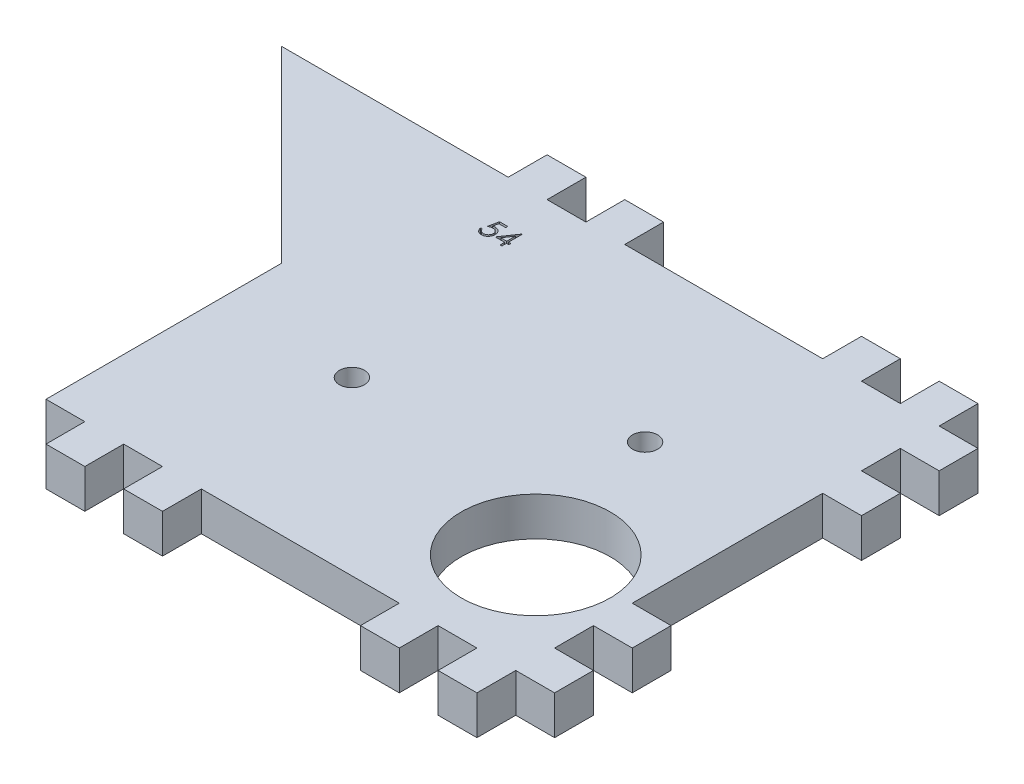
from build123d import *

# Parameters (mm, degrees)
SKETCH1_R           = 2
SKETCH1_R_2         = 11.9
BOSS_EXTRUDE1_DEPTH = 6.2
CUT_EXTRUDE1_DEPTH  = 1


with BuildPart() as part:
    # Sketch1 → Boss-Extrude1 (new body)
    with BuildSketch(Plane(origin=(0, 0, 0), x_dir=(1, 0, 0), z_dir=(0, 1, 0))):
        Polygon((-30, -6.2), (0, -36.2), (0, -73.8), (6.2, -73.8), (6.2, -80), (12.4, -80), (12.4, -73.8), (18.6, -73.8), (18.6, -80), (24.8, -80), (24.8, -73.8), (56.4, -73.8), (56.4, -80), (62.6, -80), (62.6, -73.8), (68.8, -73.8), (68.8, -80), (75, -80), (75, -73.8), (81.2, -73.8), (81.2, -67.6), (75, -67.6), (75, -61.4), (81.2, -61.4), (81.2, -55.2), (75, -55.2), (75, -24.8), (81.2, -24.8), (81.2, -18.6), (75, -18.6), (75, -12.4), (81.2, -12.4), (81.2, -6.2), (75, -6.2), (75, 0), (68.8, 0), (68.8, -6.2), (62.6, -6.2), (62.6, 0), (56.4, 0), (56.4, -6.2), (24.8, -6.2), (24.8, 0), (18.6, 0), (18.6, -6.2), (12.4, -6.2), (12.4, 0), (6.2, 0), (6.2, -6.2), align=None)
        with Locations((53.744267305, -31.89475279)):
            Circle(SKETCH1_R, mode=Mode.SUBTRACT)
        with Locations((21.41882184, -46.37677641)):
            Circle(SKETCH1_R, mode=Mode.SUBTRACT)
        with Locations((60.62, -56.23)):
            Circle(SKETCH1_R_2, mode=Mode.SUBTRACT)
    extrude(amount=BOSS_EXTRUDE1_DEPTH)

    # Sketch2 → Cut-Extrude1 (cut)
    with BuildSketch(Plane(origin=(0, 6.2, 0), x_dir=(1, 0, 0), z_dir=(0, 1, 0))):
        with BuildLine():
            Line((12.966892289, -13.0509751), (12.966892289, -13.376616125))
            Line((12.966892289, -13.376616125), (11.886934356, -13.376616125))
            Line((11.886934356, -13.376616125), (11.715845614, -14.211707271))
            add(Edge.make_bspline(
                [(11.715845614, -14.211707271), (11.749460586, -14.202426953), (11.814584277, -14.184447805), (11.910705008, -14.164485427), (12.001956507, -14.152451775), (12.061170593, -14.150808657), (12.08982398, -14.150013561)],
                knots=[0, 0, 0, 0, 0.000104595, 0.000202637, 0.000294305, 0.000380252, 0.000380252, 0.000380252, 0.000380252], degree=3))
            add(Edge.make_bspline(
                [(12.08982398, -14.150013561), (12.125278515, -14.150780946), (12.19499099, -14.152289816), (12.296989177, -14.166778565), (12.394355445, -14.189584059), (12.486886166, -14.221443389), (12.574752523, -14.262182933), (12.657146096, -14.313073593), (12.735303632, -14.372521686), (12.807822985, -14.440870376), (12.873612893, -14.516092128), (12.931457755, -14.596971054), (12.980590962, -14.682721147), (13.02010679, -14.7741617), (13.05166115, -14.870281789), (13.072663317, -14.972092774), (13.086648474, -15.078634998), (13.088210925, -15.151482715), (13.089007673, -15.188630348)],
                knots=[0, 0, 0, 0, 0.000106308, 0.000209029, 0.000308378, 0.000405929, 0.000502102, 0.000598312, 0.00069588, 0.000796219, 0.000896736, 0.000995218, 0.001094066, 0.001192613, 0.001293582, 0.001396995, 0.001504047, 0.001615439, 0.001615439, 0.001615439, 0.001615439], degree=3))
            add(Edge.make_bspline(
                [(13.089007673, -15.188630348), (13.088404355, -15.214504077), (13.087205872, -15.265901873), (13.081111153, -15.342232683), (13.069376611, -15.416947539), (13.053621604, -15.490056352), (13.03317241, -15.561420711), (13.00841734, -15.631244882), (12.978122372, -15.699094276), (12.944892482, -15.765610884), (12.907476034, -15.829290958), (12.865948388, -15.888843968), (12.822073978, -15.94516328), (12.774865007, -15.997644881), (12.723882676, -16.045943904), (12.66974442, -16.090346988), (12.612882239, -16.131605052), (12.552416412, -16.168043343), (12.489694303, -16.201574025), (12.423810134, -16.229081805), (12.356263642, -16.253674927), (12.286082647, -16.273277856), (12.213426117, -16.288638102), (12.138174285, -16.299070789), (12.06072182, -16.306669415), (12.008220916, -16.307145081), (11.981700983, -16.307385356)],
                knots=[0, 0, 0, 0, 7.7636e-05, 0.000154223, 0.000229512, 0.000304362, 0.000378447, 0.000452077, 0.000526407, 0.000601214, 0.00067506, 0.000747747, 0.00081887, 0.000889121, 0.000959302, 0.001029336, 0.001099058, 0.00116985, 0.001240974, 0.00131221, 0.00138383, 0.001456517, 0.001530612, 0.001606437, 0.001684346, 0.001763871, 0.001763871, 0.001763871, 0.001763871], degree=3))
            add(Edge.make_bspline(
                [(11.981700983, -16.307385356), (11.950065119, -16.306758667), (11.887825294, -16.305525731), (11.796638779, -16.292627534), (11.708904816, -16.274154553), (11.625329653, -16.246363079), (11.545164292, -16.211540319), (11.469487969, -16.167529221), (11.396367015, -16.11765532), (11.328773953, -16.058799571), (11.266039479, -15.994468916), (11.209881432, -15.924657342), (11.159867401, -15.850517062), (11.116798302, -15.771688023), (11.080060812, -15.688377355), (11.051200072, -15.600272919), (11.027906136, -15.507835058), (11.018051462, -15.444195802), (11.013046135, -15.411872536)],
                knots=[0, 0, 0, 0, 9.4843e-05, 0.000186593, 0.000275792, 0.000363484, 0.000450342, 0.000537514, 0.000625728, 0.000715478, 0.000805885, 0.000894984, 0.00098389, 0.001073836, 0.001164117, 0.001256635, 0.001351658, 0.001449737, 0.001449737, 0.001449737, 0.001449737], degree=3))
            Line((11.013046135, -15.411872536), (11.297982032, -15.411872536))
            add(Edge.make_bspline(
                [(11.297982032, -15.411872536), (11.304992938, -15.442149746), (11.318468288, -15.500344226), (11.34804636, -15.582106228), (11.384210404, -15.654967238), (11.42721292, -15.719891075), (11.478511877, -15.776504951), (11.537049287, -15.826957571), (11.602679007, -15.872473581), (11.675607151, -15.910412806), (11.75254473, -15.942769461), (11.833069271, -15.964315641), (11.914988214, -15.979465737), (11.970395021, -15.980982263), (11.998237441, -15.981744331)],
                knots=[0, 0, 0, 0, 9.3172e-05, 0.000179081, 0.000260145, 0.000336703, 0.000411917, 0.000488562, 0.000568128, 0.000650923, 0.00073478, 0.000817953, 0.000900557, 0.000983994, 0.000983994, 0.000983994, 0.000983994], degree=3))
            add(Edge.make_bspline(
                [(11.998237441, -15.981744331), (12.02541403, -15.980999768), (12.078924956, -15.979533718), (12.157675285, -15.968249757), (12.233705535, -15.950871103), (12.306265495, -15.924863448), (12.376624891, -15.893254311), (12.443003954, -15.852691349), (12.507322993, -15.806009761), (12.5675828, -15.752527675), (12.622772872, -15.693590881), (12.671537353, -15.63056496), (12.71215641, -15.563330392), (12.746386638, -15.493051175), (12.772379273, -15.418957055), (12.790922163, -15.341395275), (12.801810652, -15.260174257), (12.803308508, -15.204775669), (12.804071776, -15.176546013)],
                knots=[0, 0, 0, 0, 8.15e-05, 0.000160473, 0.000238226, 0.000315066, 0.000391338, 0.000469218, 0.000547964, 0.000629516, 0.000710512, 0.000789892, 0.000868102, 0.000945761, 0.001024012, 0.00110315, 0.001184644, 0.001269321, 0.001269321, 0.001269321, 0.001269321], degree=3))
            add(Edge.make_bspline(
                [(12.804071776, -15.176546013), (12.803474441, -15.151077296), (12.802305243, -15.101225905), (12.792752511, -15.028292339), (12.776136401, -14.959283222), (12.75307331, -14.89386531), (12.723791185, -14.831976902), (12.688007744, -14.773554125), (12.645051448, -14.719367005), (12.595982377, -14.669390189), (12.542226869, -14.623266624), (12.482860045, -14.583947345), (12.419124254, -14.550869363), (12.351787403, -14.522323393), (12.279247817, -14.501821288), (12.202942015, -14.486428992), (12.122046001, -14.477525056), (12.066736877, -14.476289629), (12.038306552, -14.475654587)],
                knots=[0, 0, 0, 0, 7.6388e-05, 0.000149519, 0.000220172, 0.000288967, 0.000357247, 0.000425206, 0.000494043, 0.000564207, 0.000635056, 0.000706145, 0.000777268, 0.000850264, 0.000925136, 0.001002969, 0.001083601, 0.001168886, 0.001168886, 0.001168886, 0.001168886], degree=3))
            add(Edge.make_bspline(
                [(12.038306552, -14.475654587), (12.013696738, -14.476181266), (11.962883715, -14.477268725), (11.884939437, -14.485275618), (11.803031945, -14.498192693), (11.717475224, -14.515960217), (11.628012335, -14.539211265), (11.534832071, -14.567073705), (11.437738515, -14.600385804), (11.372317437, -14.625542884), (11.338687161, -14.6384751)],
                knots=[0, 0, 0, 0, 7.3822e-05, 0.000152423, 0.000234822, 0.000322511, 0.00041445, 0.000512043, 0.000614219, 0.000722306, 0.000722306, 0.000722306, 0.000722306], degree=3))
            Line((11.338687161, -14.6384751), (11.664328186, -13.0509751))
            Line((11.664328186, -13.0509751), (12.966892289, -13.0509751))
        make_face()
        Polygon((15.147796736, -12.969564843), (15.20567434, -12.969564843), (15.20567434, -15.167641766), (15.572020494, -15.167641766), (15.572020494, -15.493282792), (15.20567434, -15.493282792), (15.20567434, -16.2259751), (14.920738443, -16.2259751), (14.920738443, -15.493282792), (13.414648699, -15.493282792), align=None)
        Polygon((14.920738443, -15.167641766), (14.920738443, -13.788755549), (13.974344212, -15.167641766), align=None, mode=Mode.SUBTRACT)
    extrude(amount=-CUT_EXTRUDE1_DEPTH, mode=Mode.SUBTRACT)


solid = part.part
